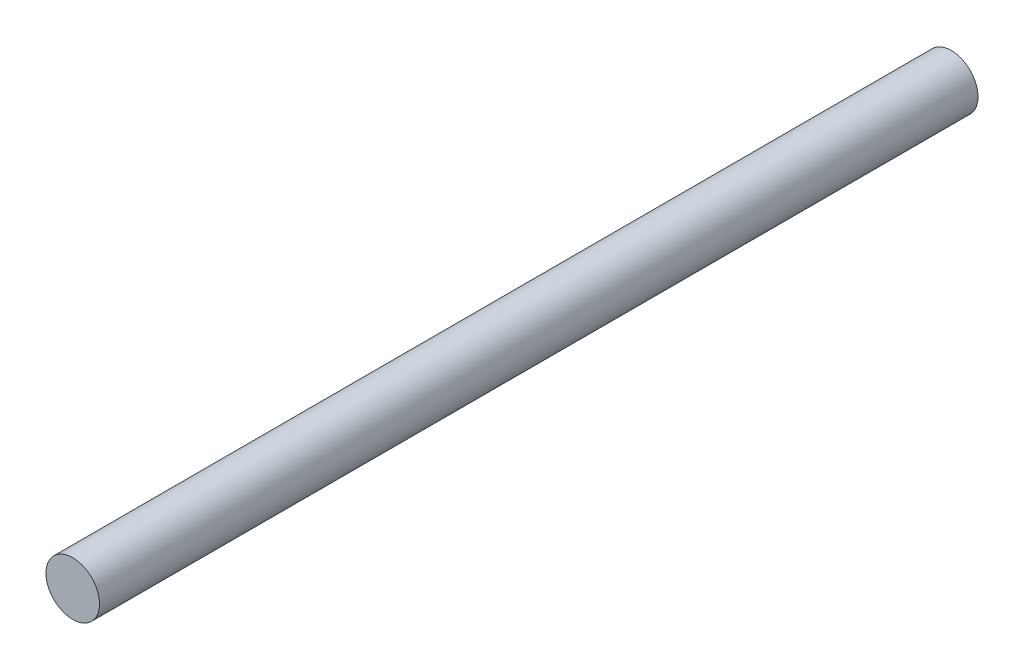
from build123d import *

# Parameters (mm, degrees)
SKETCH1_R           = 1.5875
BOSS_EXTRUDE1_DEPTH = 52.1


with BuildPart() as part:
    # Sketch1 → Boss-Extrude1 (new body)
    with BuildSketch(Plane.XY):
        Circle(SKETCH1_R)
    extrude(amount=BOSS_EXTRUDE1_DEPTH)


solid = part.part
